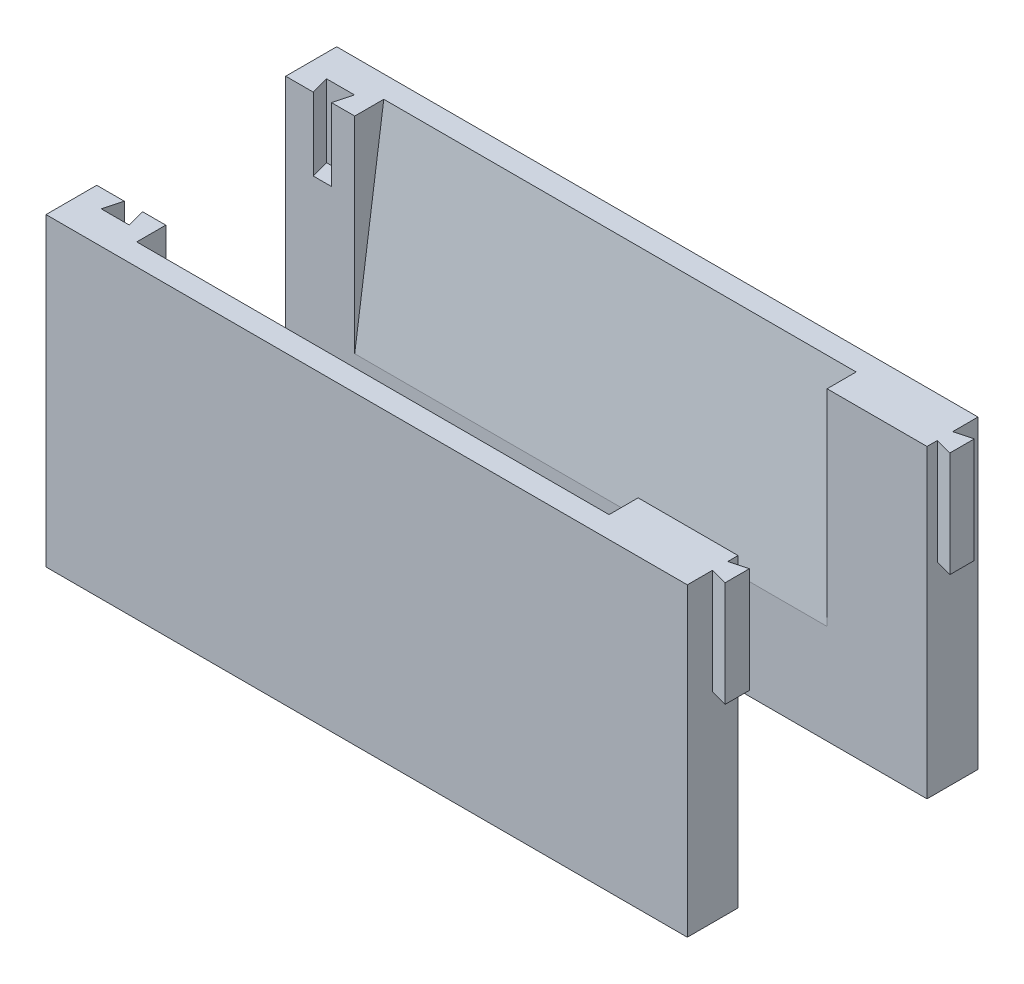
from build123d import *

# Parameters (mm, degrees)
SKETCH1_W               = 88.25
SKETCH1_H               = 42
BOSS_EXTRUDE1_DEPTH     = 5
CUT_EXTRUDE1_DEPTH      = 1
CUT_EXTRUDE1_DEPTH_BACK = 10
BOSS_EXTRUDE2_DEPTH     = 14.5
CUT_EXTRUDE2_DEPTH      = 65
SKETCH7_W               = 88.25
SKETCH7_H               = 1.9825
SKETCH7_H_2             = 2.0175
BOSS_EXTRUDE3_DEPTH     = 42


with BuildPart() as part:
    # Sketch1 → Boss-Extrude1 (new body)
    with BuildSketch(Plane.XY):
        with Locations((2.173974505, -6.951707737)):
            Rectangle(SKETCH1_W, SKETCH1_H)
    extrude(amount=BOSS_EXTRUDE1_DEPTH)

    # Sketch2 → Cut-Extrude1 (cut, two sides)
    with BuildSketch(Plane(origin=(0, 14.048292263, 0), x_dir=(1, 0, 0), z_dir=(0, 1, 0))) as cut_extrude1_sk:
        Polygon((-35.651025495, 0), (-38.151025495, 0), (-38.820898476, -2.5), (-34.981152514, -2.5), align=None)
    extrude(amount=CUT_EXTRUDE1_DEPTH, mode=Mode.SUBTRACT)
    extrude(cut_extrude1_sk.sketch, amount=-CUT_EXTRUDE1_DEPTH_BACK, mode=Mode.SUBTRACT)

    # Sketch3 → Boss-Extrude2 (add)
    with BuildSketch(Plane(origin=(0, 14.048292263, 0), x_dir=(1, 0, 0), z_dir=(0, 1, 0))):
        Polygon((46.298974505, -3.52), (48.648974505, -4.149680602), (48.648974505, -0.790319398), (46.298974505, -1.42), align=None)
    extrude(amount=-BOSS_EXTRUDE2_DEPTH)

    # Sketch6 → Cut-Extrude2 (cut)
    with BuildSketch(Plane.ZY.offset(32.451025495)):
        Polygon((-0.05, -14.629560467), (0, 14.048292263), (4, 14.048292263), align=None)
    extrude(amount=-CUT_EXTRUDE2_DEPTH, mode=Mode.SUBTRACT)


with BuildPart() as body_2:
    # Mirror3: mirrored copy
    add(part.part.mirror(Plane(origin=(0, 0, -13), x_dir=(1, 0, 0), z_dir=(0, 0, -1))))


with BuildPart() as part_1:
    add(part.part)

    add(body_2.part)  # Boss-Extrude3 merges body 2
    # Sketch7 → Boss-Extrude3 (add)
    with BuildSketch(Plane(origin=(0, 14.048292263, 0), x_dir=(1, 0, 0), z_dir=(0, 1, 0))):
        with Locations((2.173974505, -5.99125)):
            Rectangle(SKETCH7_W, SKETCH7_H)
        with Locations((2.173974505, 32.00875)):
            Rectangle(SKETCH7_W, SKETCH7_H_2)
    extrude(amount=-BOSS_EXTRUDE3_DEPTH)


solid = part_1.part
